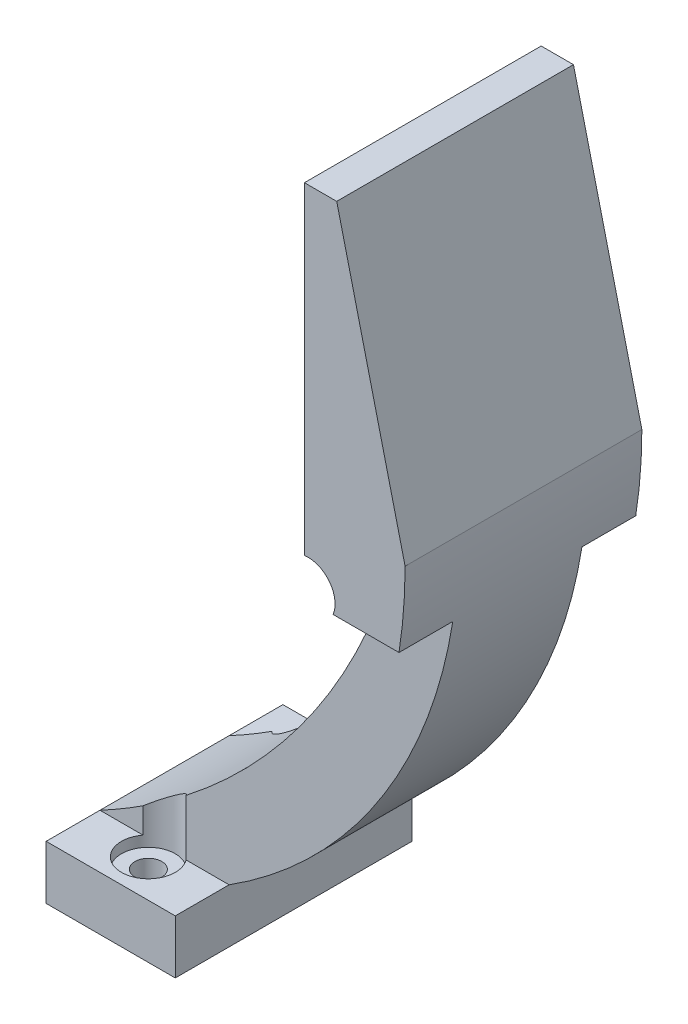
from build123d import *

# Parameters (mm, degrees)
BOSS_EXTRU_1_DEPTH      = 22
ENL_V_MAT_EXTRU_1_REACH = 35.355
ESQUISSE2_W             = 5
ESQUISSE2_H             = 31.584947586
ESQUISSE3_R             = 1.25
ENL_V_MAT_EXTRU_2_DEPTH = 4
ENL_V_MAT_EXTRU_3_REACH = 68
ESQUISSE5_R             = 2.5


with BuildPart() as part:
    # Esquisse1 → Boss.-Extru.1 (new body)
    with BuildSketch(Plane.XY):
        with BuildLine():
            Line((0, 0), (0, 5))
            ThreePointArc((0, 5), (16.362517736, 18.234357648), (26.664753317, 36.584947586))
            ThreePointArc((26.664753317, 36.584947586), (26.318927206, 39.062275696), (24, 40))
            Line((24, 40), (24, 70))
            Line((24, 70), (27, 70))
            Line((27, 70), (33.355191258, 43.816329185))
            ThreePointArc((33.355191258, 43.816329185), (27.670942171, 21.661025112), (12, 5))
            Line((12, 5), (12, 0))
            Line((12, 0), (0, 0))
        make_face()
    extrude(amount=BOSS_EXTRU_1_DEPTH)

    # Esquisse2 → Enlèv. mat.-Extru.1 (cut, up to next)
    with BuildSketch(Plane.ZY, mode=Mode.PRIVATE) as enl_v_mat_extru_1_sk1:
        with Locations((2.5, 20.792473793)):
            Rectangle(ESQUISSE2_W, ESQUISSE2_H)
    enl_v_mat_extru_1_tool1 = extrude(enl_v_mat_extru_1_sk1.sketch, amount=-ENL_V_MAT_EXTRU_1_REACH, mode=Mode.PRIVATE) & part.part
    add(enl_v_mat_extru_1_tool1.solids().sort_by_distance((0, 20.792474, 2.5))[0], mode=Mode.SUBTRACT)
    # Esquisse2 → Enlèv. mat.-Extru.1 (cut, up to next)
    with BuildSketch(Plane.ZY, mode=Mode.PRIVATE) as enl_v_mat_extru_1_sk2:
        with Locations((19.5, 20.792473793)):
            Rectangle(ESQUISSE2_W, ESQUISSE2_H)
    enl_v_mat_extru_1_tool2 = extrude(enl_v_mat_extru_1_sk2.sketch, amount=-ENL_V_MAT_EXTRU_1_REACH, mode=Mode.PRIVATE) & part.part
    add(enl_v_mat_extru_1_tool2.solids().sort_by_distance((0, 20.792474, 19.5))[0], mode=Mode.SUBTRACT)

    # Esquisse3 → Enlèv. mat.-Extru.2 (cut)
    with BuildSketch(Plane.XZ):
        with Locations((6, 18.5)):
            Circle(ESQUISSE3_R)
        with Locations((6, 3.5)):
            Circle(ESQUISSE3_R)
    extrude(amount=-ENL_V_MAT_EXTRU_2_DEPTH, mode=Mode.SUBTRACT)

    # Esquisse5 → Enlèv. mat.-Extru.3 (cut, up to next)
    with BuildSketch(Plane(origin=(0, 4, 0), x_dir=(-1, 0, 0), z_dir=(0, -1, 0)), mode=Mode.PRIVATE) as enl_v_mat_extru_3_sk1:
        with Locations((-6, -3.5)):
            Circle(ESQUISSE5_R)
    enl_v_mat_extru_3_tool1 = extrude(enl_v_mat_extru_3_sk1.sketch, amount=-ENL_V_MAT_EXTRU_3_REACH, mode=Mode.PRIVATE) & part.part
    add(enl_v_mat_extru_3_tool1.solids().sort_by_distance((6, 4, 3.5))[0], mode=Mode.SUBTRACT)
    # Esquisse5 → Enlèv. mat.-Extru.3 (cut, up to next)
    with BuildSketch(Plane(origin=(0, 4, 0), x_dir=(-1, 0, 0), z_dir=(0, -1, 0)), mode=Mode.PRIVATE) as enl_v_mat_extru_3_sk2:
        with Locations((-6, -18.5)):
            Circle(ESQUISSE5_R)
    enl_v_mat_extru_3_tool2 = extrude(enl_v_mat_extru_3_sk2.sketch, amount=-ENL_V_MAT_EXTRU_3_REACH, mode=Mode.PRIVATE) & part.part
    add(enl_v_mat_extru_3_tool2.solids().sort_by_distance((6, 4, 18.5))[0], mode=Mode.SUBTRACT)


solid = part.part
